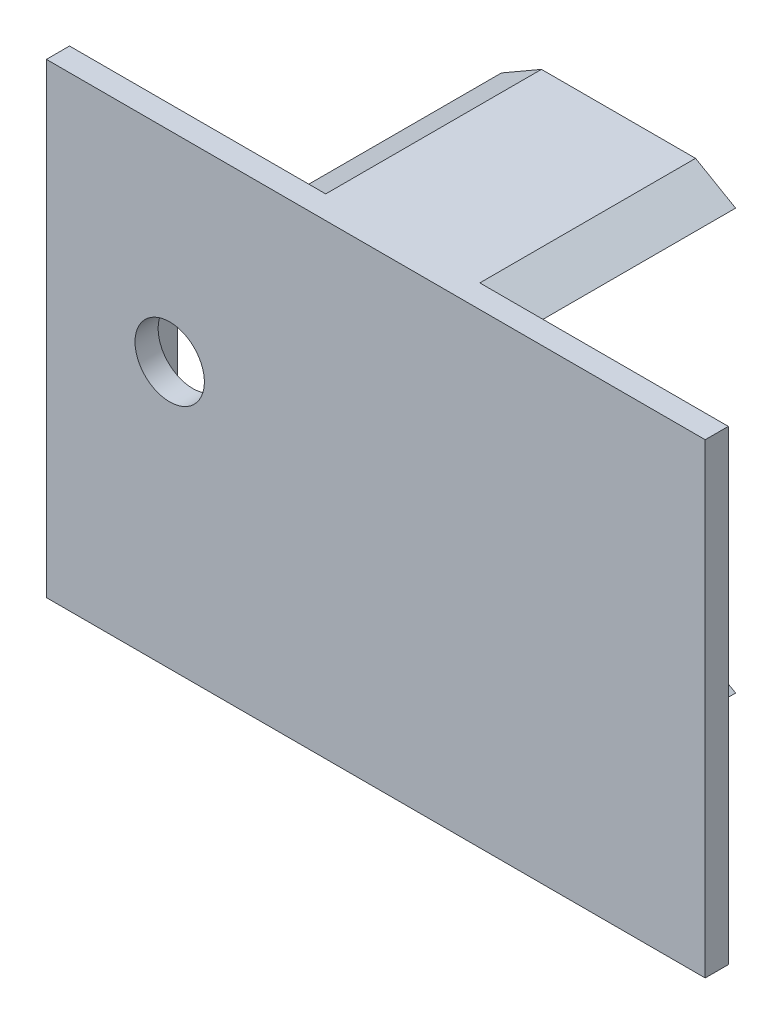
from build123d import *

# Parameters (mm, degrees)
SKETCH1_W           = 42.75
SKETCH1_H           = 30.25
BOSS_EXTRUDE1_DEPTH = 1.5
BOSS_EXTRUDE2_DEPTH = 14
SKETCH3_W           = 2
SKETCH3_H           = 7.6
BOSS_EXTRUDE3_DEPTH = 5
SKETCH4_R           = 2.25
CUT_EXTRUDE1_DEPTH  = 2.5


with BuildPart() as part:
    # Sketch1 → Boss-Extrude1 (new body)
    with BuildSketch(Plane.XY):
        Rectangle(SKETCH1_W, SKETCH1_H)
    extrude(amount=BOSS_EXTRUDE1_DEPTH)

    # Sketch2 → Boss-Extrude2 (add)
    with BuildSketch(Plane(origin=(0, 0, 0), x_dir=(-1, 0, 0), z_dir=(0, 0, -1))):
        Polygon((7.348076211, -13.625), (4.75, -12.125), (-5.25, -12.125), (-7.848076211, -13.625), (-5.25, -15.125), (4.75, -15.125), align=None)
        Polygon((-7.848076211, 13.625), (-5.25, 12.125), (4.75, 12.125), (7.348076211, 13.625), (4.75, 15.125), (-5.25, 15.125), align=None)
    extrude(amount=BOSS_EXTRUDE2_DEPTH)

    # Sketch3 → Boss-Extrude3 (add)
    with BuildSketch(Plane(origin=(0, 0, 0), x_dir=(-1, 0, 0), z_dir=(0, 0, -1))):
        with Locations((20.375, -3.125)):
            Rectangle(SKETCH3_W, SKETCH3_H)
    extrude(amount=BOSS_EXTRUDE3_DEPTH)

    # Sketch4 → Cut-Extrude1 (cut, through all)
    with BuildSketch(Plane(origin=(0, 0, 0), x_dir=(-1, 0, 0), z_dir=(0, 0, -1))):
        with Locations((13.375, 2.125)):
            Circle(SKETCH4_R)
    extrude(amount=-CUT_EXTRUDE1_DEPTH, mode=Mode.SUBTRACT)


solid = part.part
